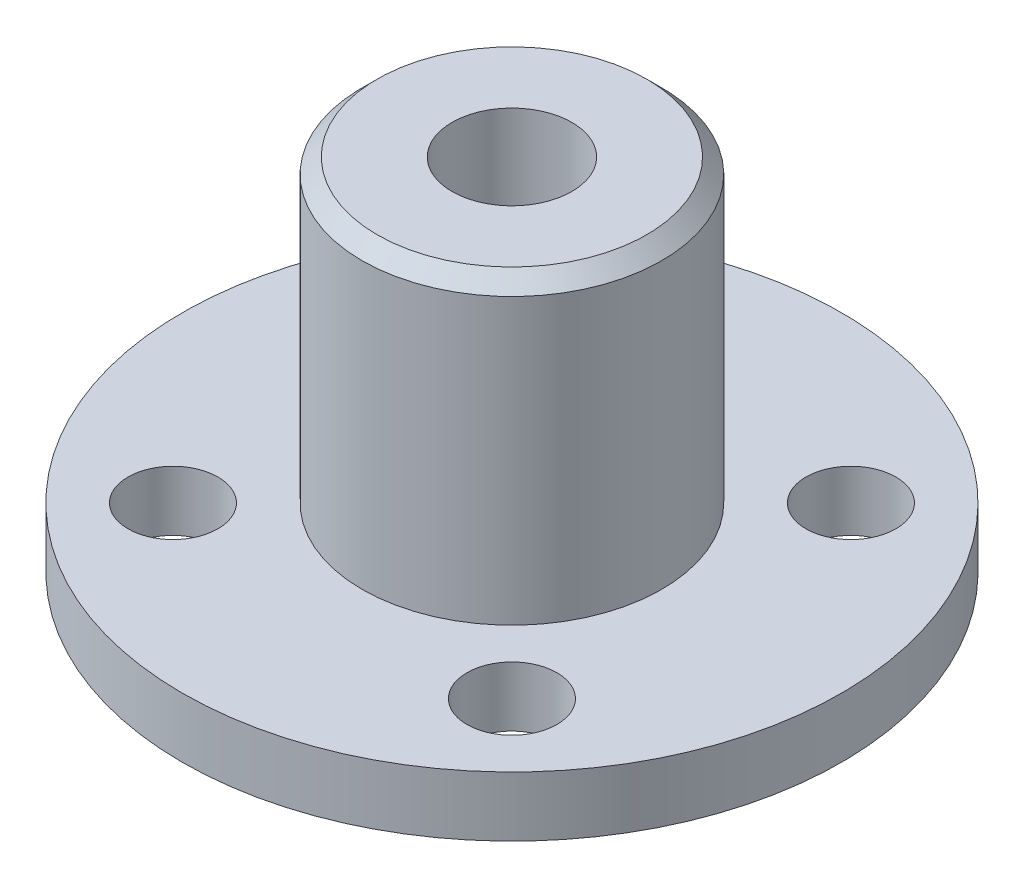
from build123d import *

# Parameters (mm, degrees)
SKETCH1_R           = 11
BOSS_EXTRUDE1_DEPTH = 2
SKETCH2_R           = 5
BOSS_EXTRUDE2_DEPTH = 10
SKETCH3_R           = 2
CUT_EXTRUDE1_DEPTH  = 13
CHAMFER1_SIZE       = 0.5
SKETCH4_R           = 1.5
CUT_EXTRUDE2_DEPTH  = 10


with BuildPart() as part:
    # Sketch1 → Boss-Extrude1 (new body)
    with BuildSketch(Plane(origin=(0, 0, 0), x_dir=(1, 0, 0), z_dir=(0, 1, 0))):
        Circle(SKETCH1_R)
    extrude(amount=BOSS_EXTRUDE1_DEPTH)

    # Sketch2 → Boss-Extrude2 (add)
    with BuildSketch(Plane(origin=(0, 2, 0), x_dir=(1, 0, 0), z_dir=(0, 1, 0))):
        Circle(SKETCH2_R)
    extrude(amount=BOSS_EXTRUDE2_DEPTH)

    # Sketch3 → Cut-Extrude1 (cut, through all)
    with BuildSketch(Plane(origin=(0, 12, 0), x_dir=(1, 0, 0), z_dir=(0, 1, 0))):
        Circle(SKETCH3_R)
    extrude(amount=-CUT_EXTRUDE1_DEPTH, mode=Mode.SUBTRACT)

    # Chamfer1
    chamfer1_edges = [part.edges().sort_by_distance(p)[0] for p in [
        (-5, 12, 0),
    ]]
    chamfer(chamfer1_edges, length=CHAMFER1_SIZE)

    # Sketch4 → Cut-Extrude2 (cut)
    with BuildSketch(Plane.XZ):
        with Locations((-5.656854249, 5.656854249)):
            Circle(SKETCH4_R)
        with Locations((5.656854249, 5.656854249)):
            Circle(SKETCH4_R)
        with Locations((5.656854249, -5.656854249)):
            Circle(SKETCH4_R)
        with Locations((-5.656854249, -5.656854249)):
            Circle(SKETCH4_R)
    extrude(amount=-CUT_EXTRUDE2_DEPTH, mode=Mode.SUBTRACT)


solid = part.part
